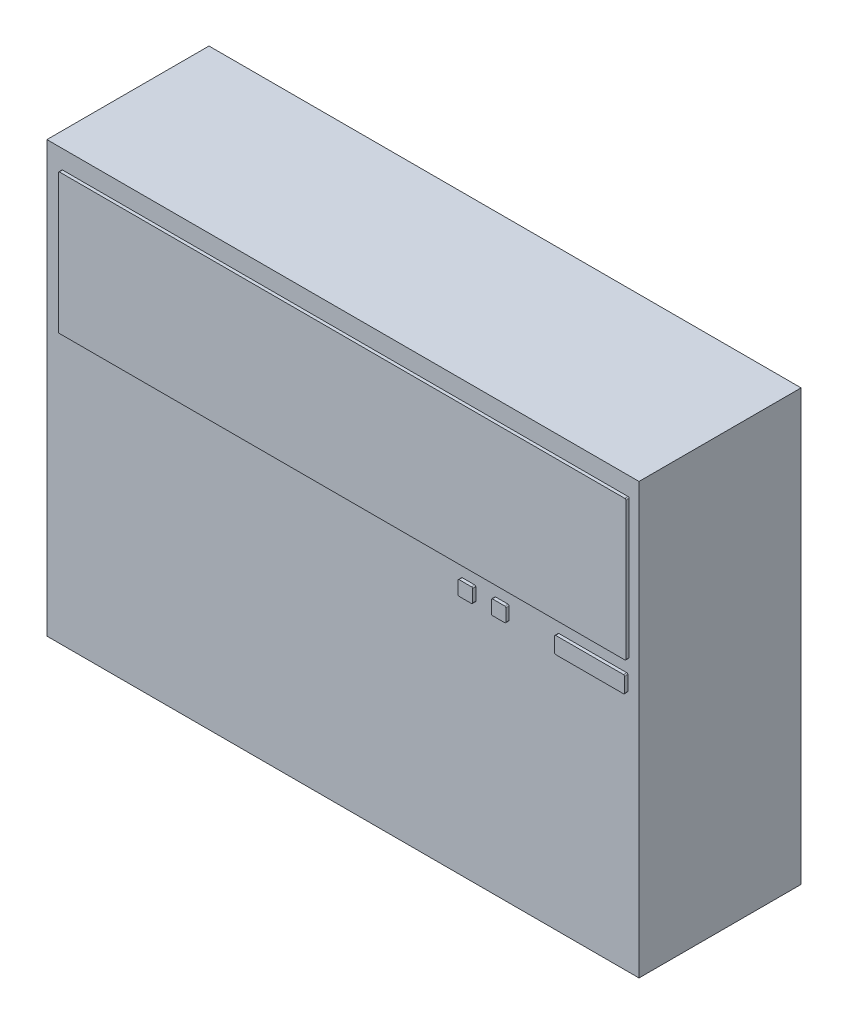
from build123d import *

# Parameters (mm, degrees)
SKETCH1_W           = 139.192
SKETCH1_H           = 101.092
BASE_EXTRUDE_DEPTH  = 38.1
BOSS_EXTRUDE1_DEPTH = 0.762


with BuildPart() as part:
    # Sketch1 → Base-Extrude (new body)
    with BuildSketch(Plane.XY):
        with Locations((-5.306370086, 124.85517785)):
            Rectangle(SKETCH1_W, SKETCH1_H)
    extrude(amount=BASE_EXTRUDE_DEPTH)

    # Sketch2 → Boss-Extrude1 (add)
    with BuildSketch(Plane.XY.offset(38.1)):
        with BuildLine():
            Line((-71.194022628, 171.043454179), (61.725007309, 171.043454179))
            ThreePointArc((61.725007309, 171.043454179), (61.904612432, 170.969059301), (61.979007309, 170.789454179))
            Line((61.979007309, 170.789454179), (61.979007309, 138.411180808))
            ThreePointArc((61.979007309, 138.411180808), (61.904612432, 138.231575686), (61.725007309, 138.157180808))
            Line((61.725007309, 138.157180808), (-71.194022628, 138.157180808))
            ThreePointArc((-71.194022628, 138.157180808), (-71.373627751, 138.231575686), (-71.448022628, 138.411180808))
            Line((-71.448022628, 138.411180808), (-71.448022628, 170.789454179))
            ThreePointArc((-71.448022628, 170.789454179), (-71.373627751, 170.969059301), (-71.194022628, 171.043454179))
        make_face()
        with BuildLine():
            Line((45.473947187, 135.025154773), (61.409083872, 135.025154773))
            ThreePointArc((61.409083872, 135.025154773), (61.588688995, 134.950759895), (61.663083872, 134.771154773))
            Line((61.663083872, 134.771154773), (61.663083872, 131.364122229))
            ThreePointArc((61.663083872, 131.364122229), (61.588688995, 131.184517106), (61.409083872, 131.110122229))
            Line((61.409083872, 131.110122229), (45.473947187, 131.110122229))
            ThreePointArc((45.473947187, 131.110122229), (45.294342065, 131.184517106), (45.219947187, 131.364122229))
            Line((45.219947187, 131.364122229), (45.219947187, 134.771154773))
            ThreePointArc((45.219947187, 134.771154773), (45.294342065, 134.950759895), (45.473947187, 135.025154773))
        make_face()
        with BuildLine():
            Line((22.766758431, 135.025154773), (25.665790975, 135.025154773))
            ThreePointArc((25.665790975, 135.025154773), (25.845396098, 134.950759895), (25.919790975, 134.771154773))
            Line((25.919790975, 134.771154773), (25.919790975, 131.872122229))
            ThreePointArc((25.919790975, 131.872122229), (25.845396098, 131.692517106), (25.665790975, 131.618122229))
            Line((25.665790975, 131.618122229), (22.766758431, 131.618122229))
            ThreePointArc((22.766758431, 131.618122229), (22.587153309, 131.692517106), (22.512758431, 131.872122229))
            Line((22.512758431, 131.872122229), (22.512758431, 134.771154773))
            ThreePointArc((22.512758431, 134.771154773), (22.587153309, 134.950759895), (22.766758431, 135.025154773))
        make_face()
        with BuildLine():
            Line((30.596823519, 135.025154773), (33.495856063, 135.025154773))
            ThreePointArc((33.495856063, 135.025154773), (33.675461186, 134.950759895), (33.749856063, 134.771154773))
            Line((33.749856063, 134.771154773), (33.749856063, 131.872122229))
            ThreePointArc((33.749856063, 131.872122229), (33.675461186, 131.692517106), (33.495856063, 131.618122229))
            Line((33.495856063, 131.618122229), (30.596823519, 131.618122229))
            ThreePointArc((30.596823519, 131.618122229), (30.417218397, 131.692517106), (30.342823519, 131.872122229))
            Line((30.342823519, 131.872122229), (30.342823519, 134.771154773))
            ThreePointArc((30.342823519, 134.771154773), (30.417218397, 134.950759895), (30.596823519, 135.025154773))
        make_face()
    extrude(amount=BOSS_EXTRUDE1_DEPTH)


solid = part.part
